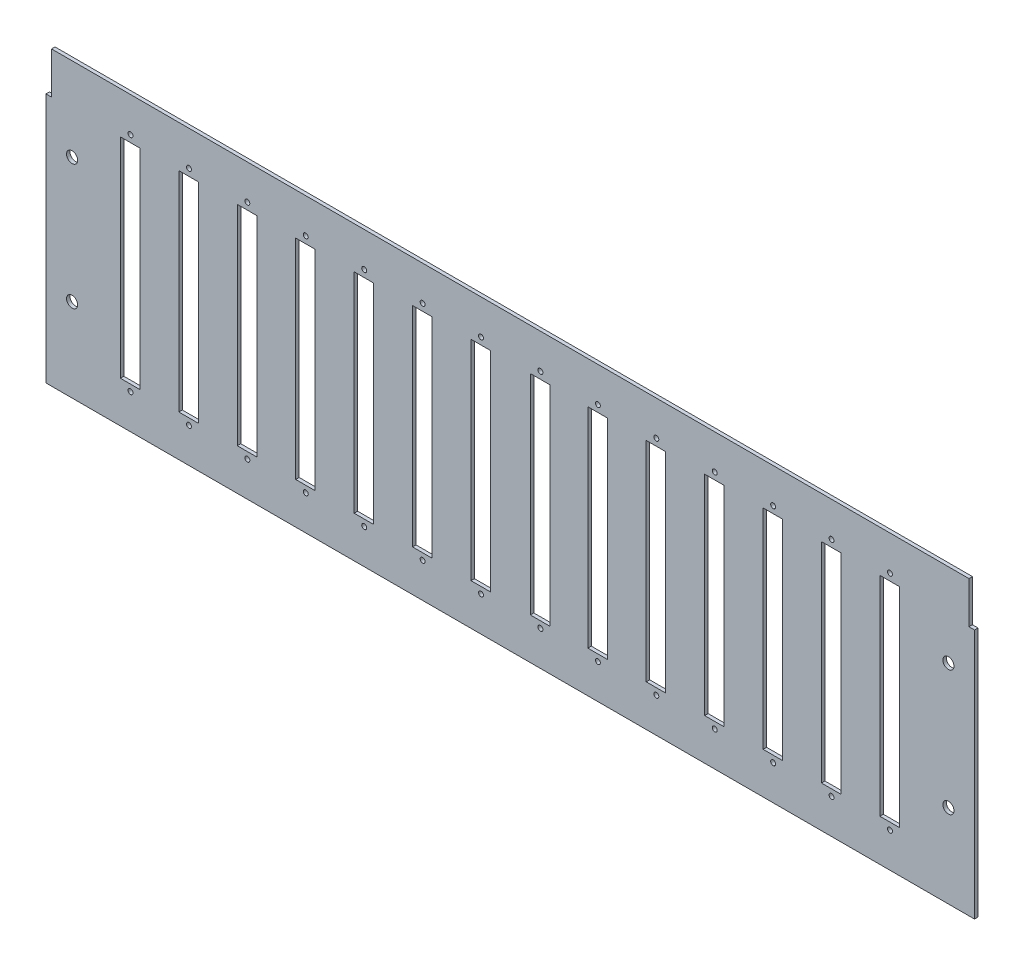
from build123d import *

# Parameters (mm, degrees)
SKETCH1_R           = 2.54
SKETCH1_R_2         = 1.1303
SKETCH1_W           = 8.89
SKETCH1_H           = 95.4405
SKETCH1_H_2         = 95.25
BOSS_EXTRUDE1_DEPTH = 1.5875


with BuildPart() as part:
    # Sketch1 → Boss-Extrude1 (new body)
    with BuildSketch(Plane.XY):
        Polygon((0, 0), (0, 114.3), (2.54, 114.3), (2.54, 133.35), (421.3352, 133.35), (421.3352, 114.3), (423.8752, 114.3), (423.8752, 0), align=None)
        with Locations((11.9126, 38.1)):
            Circle(SKETCH1_R, mode=Mode.SUBTRACT)
        with Locations((11.9126, 95.25)):
            Circle(SKETCH1_R, mode=Mode.SUBTRACT)
        with Locations((411.9626, 95.25)):
            Circle(SKETCH1_R, mode=Mode.SUBTRACT)
        with Locations((411.9626, 38.1)):
            Circle(SKETCH1_R, mode=Mode.SUBTRACT)
        with Locations((38.5826, 117.475)):
            Circle(SKETCH1_R_2, mode=Mode.SUBTRACT)
        with Locations((38.5826, 15.875)):
            Circle(SKETCH1_R_2, mode=Mode.SUBTRACT)
        with Locations((65.2526, 117.475)):
            Circle(SKETCH1_R_2, mode=Mode.SUBTRACT)
        with Locations((65.2526, 15.875)):
            Circle(SKETCH1_R_2, mode=Mode.SUBTRACT)
        with Locations((91.9226, 117.475)):
            Circle(SKETCH1_R_2, mode=Mode.SUBTRACT)
        with Locations((91.9226, 15.875)):
            Circle(SKETCH1_R_2, mode=Mode.SUBTRACT)
        with Locations((118.5926, 117.475)):
            Circle(SKETCH1_R_2, mode=Mode.SUBTRACT)
        with Locations((118.5926, 15.875)):
            Circle(SKETCH1_R_2, mode=Mode.SUBTRACT)
        with Locations((145.2626, 117.475)):
            Circle(SKETCH1_R_2, mode=Mode.SUBTRACT)
        with Locations((145.2626, 15.875)):
            Circle(SKETCH1_R_2, mode=Mode.SUBTRACT)
        with Locations((171.9326, 117.475)):
            Circle(SKETCH1_R_2, mode=Mode.SUBTRACT)
        with Locations((171.9326, 15.875)):
            Circle(SKETCH1_R_2, mode=Mode.SUBTRACT)
        with Locations((198.6026, 117.475)):
            Circle(SKETCH1_R_2, mode=Mode.SUBTRACT)
        with Locations((198.6026, 15.875)):
            Circle(SKETCH1_R_2, mode=Mode.SUBTRACT)
        with Locations((225.704188438, 117.475)):
            Circle(SKETCH1_R_2, mode=Mode.SUBTRACT)
        with Locations((225.704188438, 15.875)):
            Circle(SKETCH1_R_2, mode=Mode.SUBTRACT)
        with Locations((251.9426, 117.475)):
            Circle(SKETCH1_R_2, mode=Mode.SUBTRACT)
        with Locations((251.9426, 15.875)):
            Circle(SKETCH1_R_2, mode=Mode.SUBTRACT)
        with Locations((278.6126, 117.475)):
            Circle(SKETCH1_R_2, mode=Mode.SUBTRACT)
        with Locations((278.6126, 15.875)):
            Circle(SKETCH1_R_2, mode=Mode.SUBTRACT)
        with Locations((305.2826, 117.475)):
            Circle(SKETCH1_R_2, mode=Mode.SUBTRACT)
        with Locations((305.2826, 15.875)):
            Circle(SKETCH1_R_2, mode=Mode.SUBTRACT)
        with Locations((331.9526, 117.475)):
            Circle(SKETCH1_R_2, mode=Mode.SUBTRACT)
        with Locations((331.9526, 15.875)):
            Circle(SKETCH1_R_2, mode=Mode.SUBTRACT)
        with Locations((358.6226, 117.475)):
            Circle(SKETCH1_R_2, mode=Mode.SUBTRACT)
        with Locations((358.6226, 15.875)):
            Circle(SKETCH1_R_2, mode=Mode.SUBTRACT)
        with Locations((385.2926, 117.475)):
            Circle(SKETCH1_R_2, mode=Mode.SUBTRACT)
        with Locations((385.2926, 15.875)):
            Circle(SKETCH1_R_2, mode=Mode.SUBTRACT)
        with Locations((38.42385, 66.57975)):
            Rectangle(SKETCH1_W, SKETCH1_H, mode=Mode.SUBTRACT)
        with Locations((65.09385, 66.57975)):
            Rectangle(SKETCH1_W, SKETCH1_H, mode=Mode.SUBTRACT)
        with Locations((91.76385, 66.57975)):
            Rectangle(SKETCH1_W, SKETCH1_H, mode=Mode.SUBTRACT)
        with Locations((118.43385, 66.57975)):
            Rectangle(SKETCH1_W, SKETCH1_H, mode=Mode.SUBTRACT)
        with Locations((145.10385, 66.57975)):
            Rectangle(SKETCH1_W, SKETCH1_H, mode=Mode.SUBTRACT)
        with Locations((251.78385, 66.57975)):
            Rectangle(SKETCH1_W, SKETCH1_H, mode=Mode.SUBTRACT)
        with Locations((171.77385, 66.57975)):
            Rectangle(SKETCH1_W, SKETCH1_H, mode=Mode.SUBTRACT)
        with Locations((198.44385, 66.57975)):
            Rectangle(SKETCH1_W, SKETCH1_H, mode=Mode.SUBTRACT)
        with Locations((225.545438438, 66.57975)):
            Rectangle(SKETCH1_W, SKETCH1_H, mode=Mode.SUBTRACT)
        with Locations((278.45385, 66.57975)):
            Rectangle(SKETCH1_W, SKETCH1_H, mode=Mode.SUBTRACT)
        with Locations((305.12385, 66.57975)):
            Rectangle(SKETCH1_W, SKETCH1_H, mode=Mode.SUBTRACT)
        with Locations((331.79385, 66.57975)):
            Rectangle(SKETCH1_W, SKETCH1_H, mode=Mode.SUBTRACT)
        with Locations((358.46385, 66.57975)):
            Rectangle(SKETCH1_W, SKETCH1_H, mode=Mode.SUBTRACT)
        with Locations((385.13385, 66.675)):
            Rectangle(SKETCH1_W, SKETCH1_H_2, mode=Mode.SUBTRACT)
    extrude(amount=BOSS_EXTRUDE1_DEPTH)


solid = part.part
